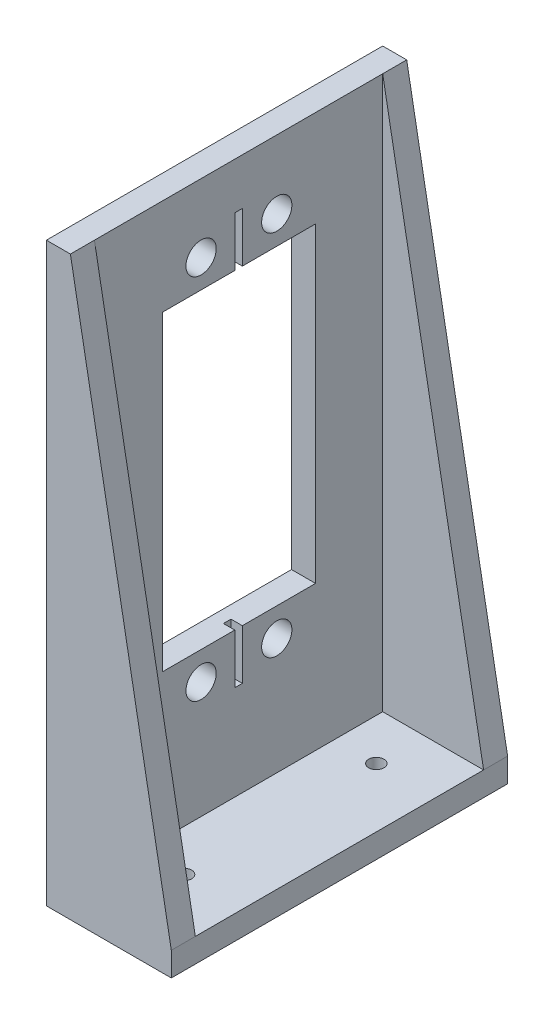
from build123d import *

# Parameters (mm, degrees)
BOSS_EXTRUDE1_DEPTH = 22.225
BOSS_EXTRUDE2_DEPTH = 3.175
SKETCH4_R           = 1.000000032
CUT_EXTRUDE2_DEPTH  = 4.175
SKETCH5_R           = 2.000000064
CUT_EXTRUDE3_DEPTH  = 4.175
SKETCH6_W           = 20.253999878
SKETCH6_H           = 41.153999988
CUT_EXTRUDE4_DEPTH  = 4.175
SKETCH7_W           = 1.500000048
SKETCH7_H           = 1.000000032
CUT_EXTRUDE5_DEPTH  = 6.604
CUT_EXTRUDE6_START  = 41.154
SKETCH7_2_W         = 1.500000048
SKETCH7_2_H         = 1.000000032
CUT_EXTRUDE6_DEPTH  = 6.604


with BuildPart() as part:
    # Sketch1 → Boss-Extrude1 (new body, symmetric)
    with BuildSketch(Plane.XY):
        Polygon((0, 0), (0, 76.2), (3.175, 76.2), (3.175, 3.175), (16.51, 3.175), (16.51, 0), align=None)
    extrude(amount=BOSS_EXTRUDE1_DEPTH, both=True)

    # Sketch3 → Boss-Extrude2 (add)
    with BuildSketch(Plane.XY.offset(22.225)):
        Polygon((3.175, 76.2), (16.51, 3.175), (3.175, 3.175), align=None)
    boss_extrude2 = extrude(amount=-BOSS_EXTRUDE2_DEPTH)

    # Mirror1: Boss-Extrude2 across plane
    add(boss_extrude2.mirror(Plane.XY))

    # Sketch4 → Cut-Extrude2 (cut, through all)
    with BuildSketch(Plane(origin=(0, 3.175, 0), x_dir=(1, 0, 0), z_dir=(0, 1, 0))):
        with Locations((8.679999912, 12.7)):
            Circle(SKETCH4_R)
        with Locations((8.679999912, -12.7)):
            Circle(SKETCH4_R)
    extrude(amount=-CUT_EXTRUDE2_DEPTH, mode=Mode.SUBTRACT)

    # Sketch5 → Cut-Extrude3 (cut, through all)
    with BuildSketch(Plane(origin=(3.175, 0, 0), x_dir=(0, 0, -1), z_dir=(1, 0, 0))):
        with Locations((-4.953, 18.574999934)):
            Circle(SKETCH5_R)
        with Locations((5.047000066, 18.574999934)):
            Circle(SKETCH5_R)
        with Locations((-4.953, 67.175000016)):
            Circle(SKETCH5_R)
        with Locations((5.047000066, 67.175000016)):
            Circle(SKETCH5_R)
    extrude(amount=-CUT_EXTRUDE3_DEPTH, mode=Mode.SUBTRACT)

    # Sketch6 → Cut-Extrude4 (cut, through all)
    with BuildSketch(Plane(origin=(3.175, 0, 0), x_dir=(0, 0, -1), z_dir=(1, 0, 0))):
        with Locations((0.047000033, 42.874999975)):
            Rectangle(SKETCH6_W, SKETCH6_H)
    extrude(amount=-CUT_EXTRUDE4_DEPTH, mode=Mode.SUBTRACT)

    # Sketch7 → Cut-Extrude5 (cut)
    with BuildSketch(Plane.XZ.offset(-63.451999969)):
        with Locations((2.424999976, 0)):
            Rectangle(SKETCH7_W, SKETCH7_H)
    extrude(amount=-CUT_EXTRUDE5_DEPTH, mode=Mode.SUBTRACT)

    # Sketch7_2 → Cut-Extrude6 (cut)
    with BuildSketch(Plane.XZ.offset(-63.451999969).offset(CUT_EXTRUDE6_START)):
        with Locations((2.424999976, 0)):
            Rectangle(SKETCH7_2_W, SKETCH7_2_H)
    extrude(amount=CUT_EXTRUDE6_DEPTH, mode=Mode.SUBTRACT)


solid = part.part
